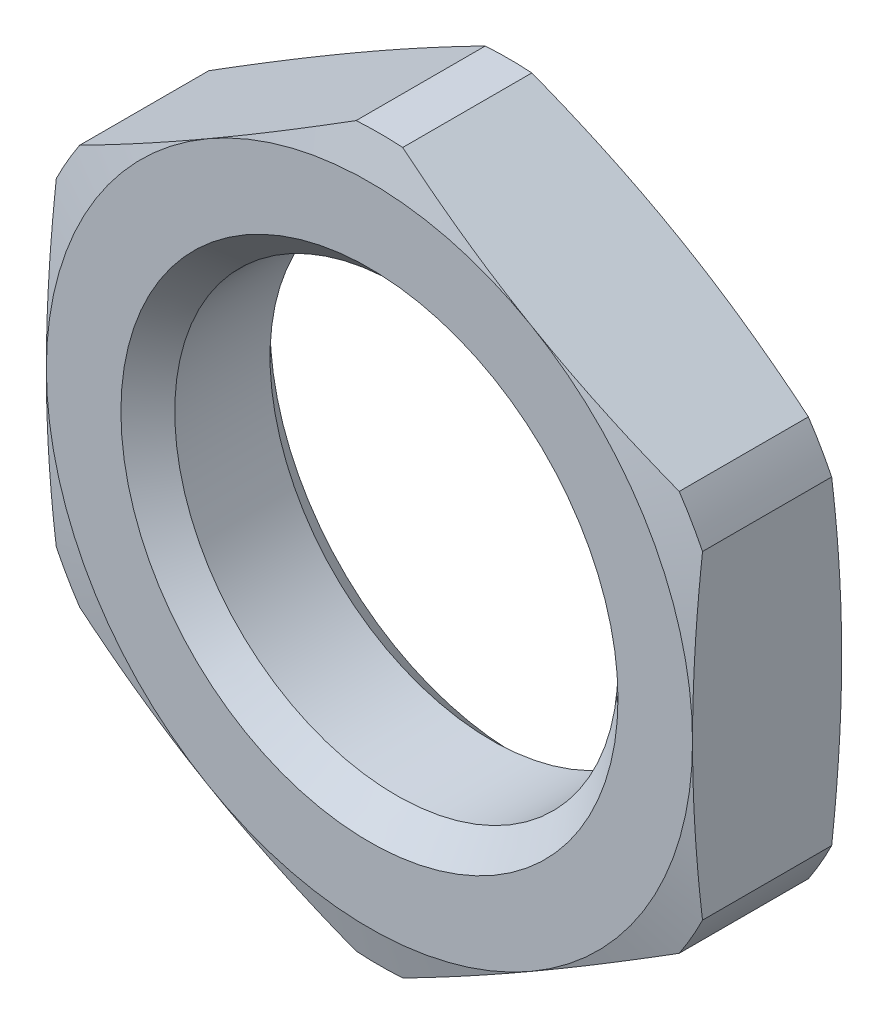
from build123d import *

# Parameters (mm, degrees)
SCHNITT_LINEAR_AUSTRAGEN1_DEPTH      = 10
SCHNITT_LINEAR_AUSTRAGEN1_DEPTH_BACK = 10
SKIZZE2_W                            = 69.6667
SKIZZE2_H                            = 68.6667


with BuildPart() as part:
    # Skizze1 → Rotation1 (revolve)
    with BuildSketch(Plane(origin=(0, 0, 0), x_dir=(0, 0, -1), z_dir=(1, 0, 0))):
        Polygon((-3, 6.5), (-3, 5), (-2.4585, 4.4585), (-0.5415, 4.4585), (0, 5), (0, 6.5), (-0.200961894, 7.25), (-2.799038106, 7.25), align=None)
    revolve(axis=Axis((0, 0, 0), (0, 0, 1)))

    # Skizze2 → Schnitt-Linear austragen1 (cut, two sides: drawn at the far end of the back side and taken through both)
    with BuildSketch(Plane.XY.offset(-SCHNITT_LINEAR_AUSTRAGEN1_DEPTH_BACK)):
        with Locations((-1.75005, -1.16665)):
            Rectangle(SKIZZE2_W, SKIZZE2_H)
        Polygon((-6.5, -3.75277675), (0, -7.505553499), (6.5, -3.75277675), (6.5, 3.75277675), (0, 7.505553499), (-6.5, 3.75277675), align=None, mode=Mode.SUBTRACT)
    extrude(amount=SCHNITT_LINEAR_AUSTRAGEN1_DEPTH + SCHNITT_LINEAR_AUSTRAGEN1_DEPTH_BACK, mode=Mode.SUBTRACT)


solid = part.part
